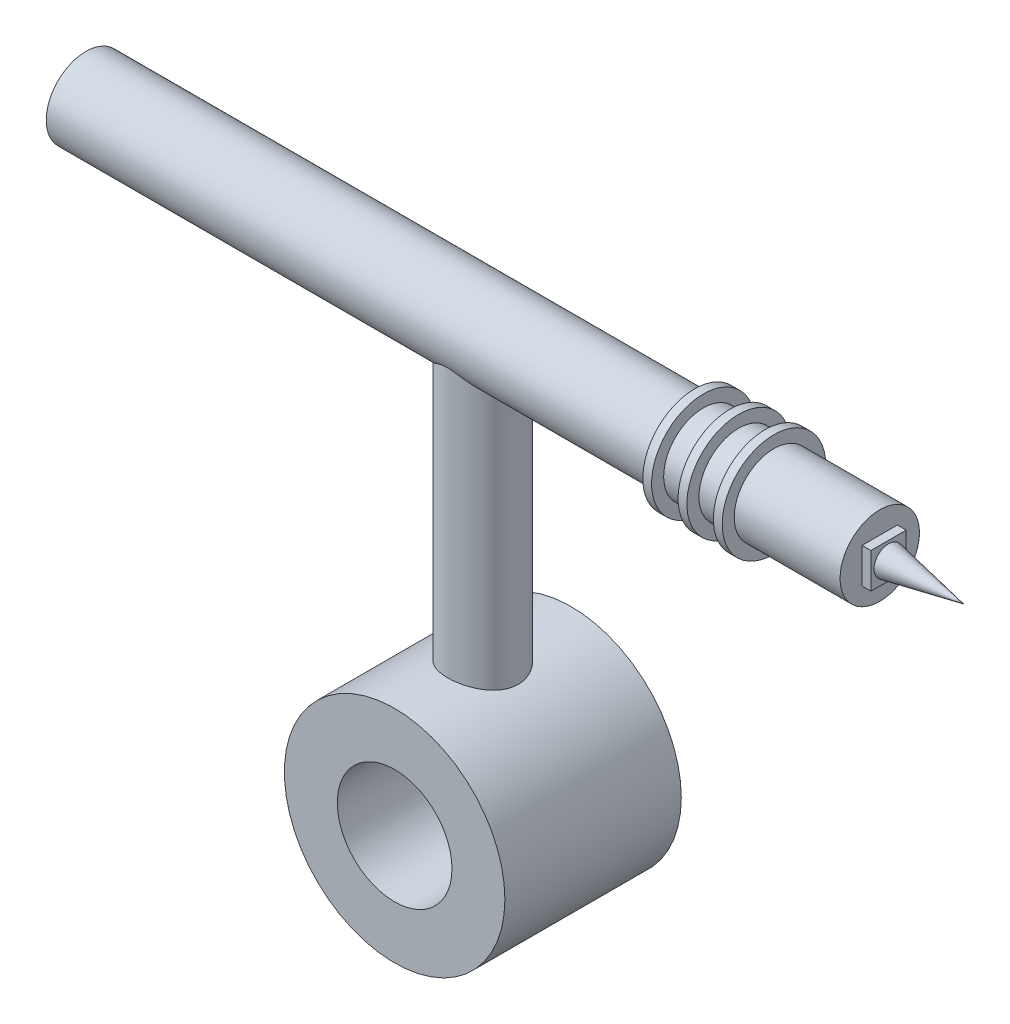
from build123d import *

# Parameters (mm, degrees)
SKETCH2_R           = 6.25
EXTRUDE1_DEPTH      = 5
SKETCH3_R           = 2
EXTRUDE2_DEPTH      = 22.5
EXTRUDE3_DEPTH      = 22.5
EXTRUDE3_DEPTH_BACK = 22.5
SKETCH4_R           = 2.25
SKETCH5_R           = 2.933820517
EXTRUDE4_DEPTH      = 0.5
LPATTERN1_COUNT     = 3
LPATTERN1_PITCH     = 2
SKETCH9_W           = 2
SKETCH9_H           = 2
EXTRUDE6_DEPTH      = 0.5
SKETCH7_R           = 3.25
CUT_EXTRUDE1_DEPTH  = 39.599438251


with BuildPart() as part:
    # Sketch2 → Extrude1 (new, symmetric)
    with BuildSketch(Plane.XY):
        Circle(SKETCH2_R)
    extrude(amount=EXTRUDE1_DEPTH, both=True)

    # Sketch3 → Extrude2 (add)
    with BuildSketch(Plane(origin=(0, 0, 0), x_dir=(-1, 0, 0), z_dir=(0, 1, 0))):
        Circle(SKETCH3_R)
    extrude(amount=EXTRUDE2_DEPTH)

    # Sketch4 → Extrude3 (add, two sides: drawn at the far end of the back side and taken through both)
    with BuildSketch(Plane(origin=(0, 0, 0), x_dir=(0, 0, -1), z_dir=(1, 0, 0)).offset(-EXTRUDE3_DEPTH_BACK)):
        with Locations((0, 22.5)):
            Circle(SKETCH4_R)
    extrude(amount=EXTRUDE3_DEPTH + EXTRUDE3_DEPTH_BACK)

    # Sketch5 → Extrude4 (add)
    with BuildSketch(Plane(origin=(12, 0, 0), x_dir=(0, 0, -1), z_dir=(1, 0, 0))):
        with Locations((0, 22.5)):
            Circle(SKETCH5_R)
    extrude4 = extrude(amount=EXTRUDE4_DEPTH)

    # LPattern1: Extrude4 ×3
    with Locations(*[(i * LPATTERN1_PITCH, 0, 0) for i in range(1, LPATTERN1_COUNT)]):
        add(extrude4)

    # Sketch9 → Extrude6 (add)
    with BuildSketch(Plane(origin=(22.5, 0, 0), x_dir=(0, 0, -1), z_dir=(1, 0, 0))):
        with Locations((0, 22.5)):
            Rectangle(SKETCH9_W, SKETCH9_H)
    extrude(amount=EXTRUDE6_DEPTH)

    # Extrude5 cone 1 section (through the dimple's axis) → Extrude5 (revolve)
    with BuildSketch(Plane(origin=(22.5, 22.5, 0), x_dir=(0, 0, 1), z_dir=(0, 1, 0))):
        Polygon((0, 0), (0.925, 0), (0, 4.758712465), align=None)
    revolve(axis=Axis((22.5, 22.5, 0), (1, 0, 0)))

    # Sketch7 → Cut-Extrude1 (cut, through all)
    with BuildSketch(Plane.XY.offset(5)):
        Circle(SKETCH7_R)
    extrude(amount=-CUT_EXTRUDE1_DEPTH, mode=Mode.SUBTRACT)


solid = part.part
